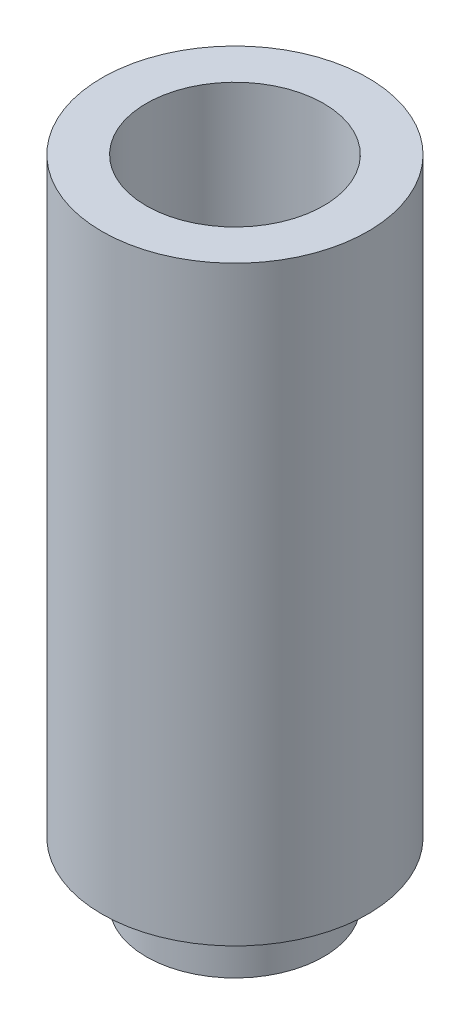
from build123d import *

# Parameters (mm, degrees)
SKETCH1_R           = 6
BOSS_EXTRUDE1_DEPTH = 4
SKETCH2_R           = 9
BOSS_EXTRUDE2_DEPTH = 40
SKETCH3_R           = 3.5
CUT_EXTRUDE1_DEPTH  = 4
SKETCH4_R           = 6
CUT_EXTRUDE2_DEPTH  = 10


with BuildPart() as part:
    # Sketch1 → Boss-Extrude1 (new body)
    with BuildSketch(Plane(origin=(0, 0, 0), x_dir=(1, 0, 0), z_dir=(0, 1, 0))):
        Circle(SKETCH1_R)
    extrude(amount=BOSS_EXTRUDE1_DEPTH)

    # Sketch2 → Boss-Extrude2 (add)
    with BuildSketch(Plane(origin=(0, 4, 0), x_dir=(1, 0, 0), z_dir=(0, 1, 0))):
        Circle(SKETCH2_R)
    extrude(amount=BOSS_EXTRUDE2_DEPTH)

    # Sketch3 → Cut-Extrude1 (cut)
    with BuildSketch(Plane.XZ):
        Circle(SKETCH3_R)
    extrude(amount=-CUT_EXTRUDE1_DEPTH, mode=Mode.SUBTRACT)

    # Sketch4 → Cut-Extrude2 (cut)
    with BuildSketch(Plane(origin=(0, 44, 0), x_dir=(1, 0, 0), z_dir=(0, 1, 0))):
        Circle(SKETCH4_R)
    extrude(amount=-CUT_EXTRUDE2_DEPTH, mode=Mode.SUBTRACT)


solid = part.part
